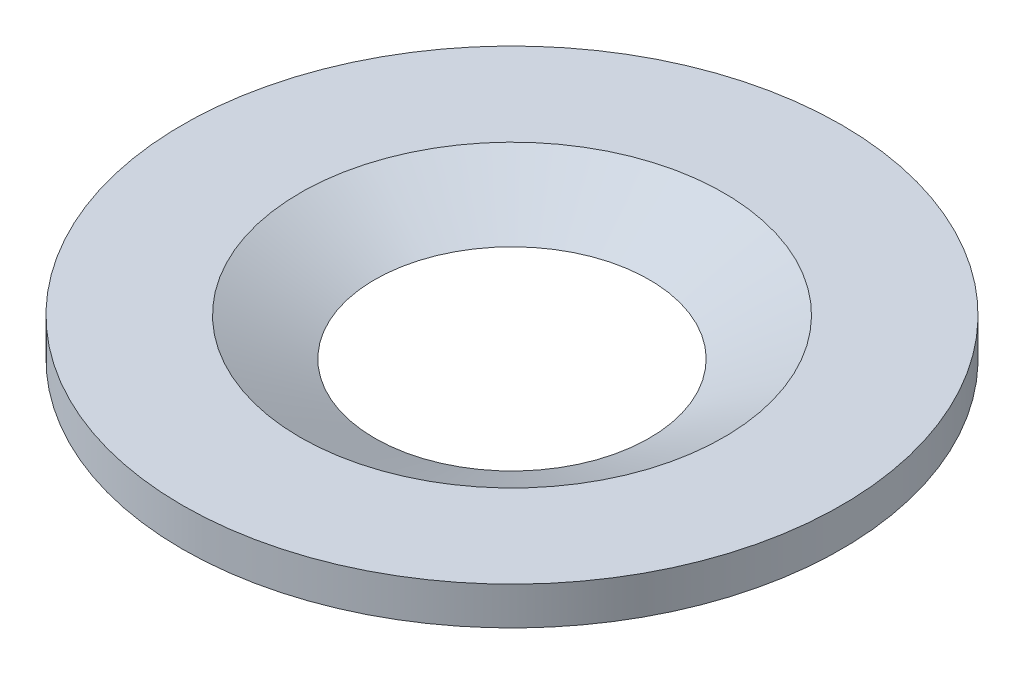
from build123d import *

# Parameters (mm, degrees)
SKETCH1_R           = 83.82
SKETCH1_R_2         = 34.925
BOSS_EXTRUDE1_DEPTH = 9.652


with BuildPart() as part:
    # Sketch1 → Boss-Extrude1 (new body)
    with BuildSketch(Plane(origin=(0, 0, 0), x_dir=(1, 0, 0), z_dir=(0, 1, 0))):
        Circle(SKETCH1_R)
        Circle(SKETCH1_R_2, mode=Mode.SUBTRACT)
    extrude(amount=BOSS_EXTRUDE1_DEPTH)

    # Sketch3 → Cut-Revolve1 (revolve, cut)
    with BuildSketch(Plane.XY):
        Polygon((-34.925, 0), (-53.868116599, 9.652), (-34.925, 9.652), align=None)
    revolve(axis=Axis((0, 23.278593151, 0), (0, -1, 0)), mode=Mode.SUBTRACT)


solid = part.part
